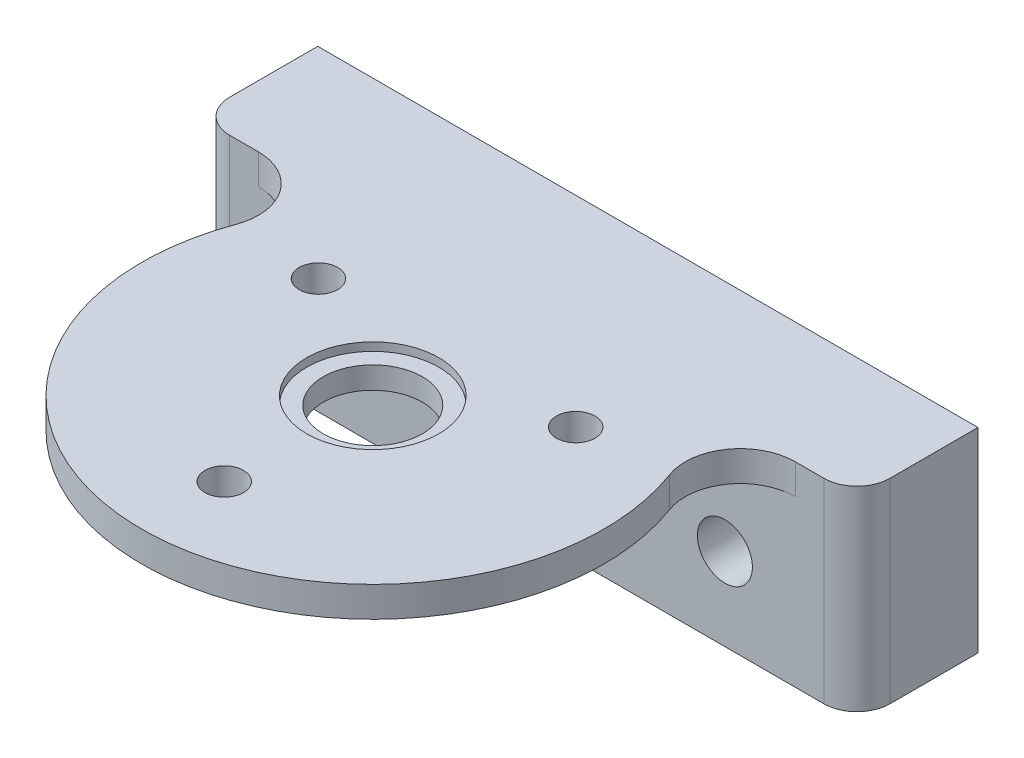
from build123d import *

# Parameters (mm, degrees)
SKETCH1_R                = 6
SKETCH1_R_2              = 4.5
BOSS_EXTRUDE1_DEPTH      = 2
SKETCH1_5_R              = 21
SKETCH1_5_R_2            = 6
BOSS_EXTRUDE3_DEPTH      = 2.75
SKETCH2_R                = 1.75
CUT_EXTRUDE1_DEPTH       = 4.5
CIRPATTERN1_COUNT        = 3
SKETCH9_W                = 60
SKETCH9_H                = 11
BOSS_EXTRUDE7_DEPTH      = 15
BOSS_EXTRUDE7_DEPTH_BACK = 2.75
CUT_EXTRUDE3_REACH       = 13
SKETCH10_R               = 2.5
FILLET4_R                = 3
FILLET5_R                = 5


with BuildPart() as part:
    # Sketch1 → Boss-Extrude1 (new body)
    with BuildSketch(Plane(origin=(0, 0, 0), x_dir=(1, 0, 0), z_dir=(0, 1, 0))):
        Circle(SKETCH1_R)
        Circle(SKETCH1_R_2, mode=Mode.SUBTRACT)
    extrude(amount=BOSS_EXTRUDE1_DEPTH)

    # Sketch1_5 → Boss-Extrude3 (add)
    with BuildSketch(Plane(origin=(0, 0, 0), x_dir=(1, 0, 0), z_dir=(0, 1, 0))):
        Circle(SKETCH1_5_R)
        Circle(SKETCH1_5_R_2, mode=Mode.SUBTRACT)
    extrude(amount=BOSS_EXTRUDE3_DEPTH)

    # Sketch2 → Cut-Extrude1 (cut)
    with BuildSketch(Plane(origin=(0, 2.75, 0), x_dir=(1, 0, 0), z_dir=(0, 1, 0))):
        with Locations((0, -13.5)):
            Circle(SKETCH2_R)
    cut_extrude1 = extrude(amount=-CUT_EXTRUDE1_DEPTH, mode=Mode.SUBTRACT)

    # CirPattern1: Cut-Extrude1 ×3 about axis
    cirpattern1_axis = Axis((0, 0, 0), (0, 1, 0))
    for i in range(1, CIRPATTERN1_COUNT):
        add(cut_extrude1.rotate(cirpattern1_axis, i * 360 / CIRPATTERN1_COUNT), mode=Mode.SUBTRACT)

    # Sketch9 → Boss-Extrude7 (add, two sides)
    with BuildSketch(Plane.XZ) as boss_extrude7_sk:
        with Locations((0, -19.5)):
            Rectangle(SKETCH9_W, SKETCH9_H)
    extrude(amount=BOSS_EXTRUDE7_DEPTH)
    extrude(boss_extrude7_sk.sketch, amount=-BOSS_EXTRUDE7_DEPTH_BACK)

    # Sketch10 → Cut-Extrude3 (cut, up to next)
    with BuildSketch(Plane.XY.offset(-14), mode=Mode.PRIVATE) as cut_extrude3_sk1:
        with Locations((-18, -7.5)):
            Circle(SKETCH10_R)
    cut_extrude3_tool1 = extrude(cut_extrude3_sk1.sketch, amount=-CUT_EXTRUDE3_REACH, mode=Mode.PRIVATE) & part.part
    add(cut_extrude3_tool1.solids().sort_by_distance((-18, -7.5, -14))[0], mode=Mode.SUBTRACT)
    # Sketch10 → Cut-Extrude3 (cut, up to next)
    with BuildSketch(Plane.XY.offset(-14), mode=Mode.PRIVATE) as cut_extrude3_sk2:
        with Locations((18, -7.5)):
            Circle(SKETCH10_R)
    cut_extrude3_tool2 = extrude(cut_extrude3_sk2.sketch, amount=-CUT_EXTRUDE3_REACH, mode=Mode.PRIVATE) & part.part
    add(cut_extrude3_tool2.solids().sort_by_distance((18, -7.5, -14))[0], mode=Mode.SUBTRACT)

    # Fillet4
    fillet4_edges = [part.edges().sort_by_distance(p)[0] for p in [
        (-30, -6.125, -14),
        (30, -6.125, -14),
    ]]
    fillet(fillet4_edges, radius=FILLET4_R)

    # Fillet5
    fillet5_edges = [part.edges().sort_by_distance(p)[0] for p in [
        (-15.652475842, 1.375, -14),
        (15.652475842, 1.375, -14),
    ]]
    fillet(fillet5_edges, radius=FILLET5_R)


solid = part.part
